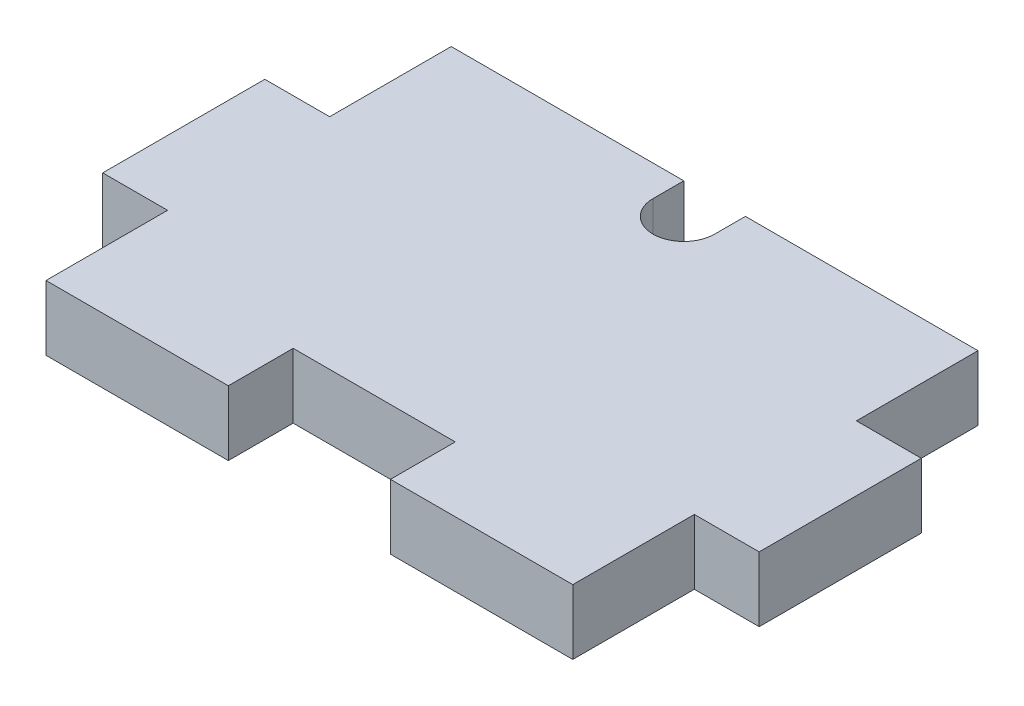
from build123d import *

# Parameters (mm, degrees)
SKETCH1_W           = 32.5
SKETCH1_H           = 25
BOSS_EXTRUDE1_DEPTH = 4
SKETCH2_R           = 1.9
SKETCH2_W           = 3.8
SKETCH2_H           = 1.9
CUT_EXTRUDE5_DEPTH  = 5
SKETCH3_W           = 4
SKETCH3_H           = 10
BOSS_EXTRUDE2_DEPTH = 4
SKETCH4_W           = 10
SKETCH4_H           = 4
CUT_EXTRUDE6_DEPTH  = 5


with BuildPart() as part:
    # Sketch1 → Boss-Extrude1 (new body)
    with BuildSketch(Plane(origin=(0, 0, 0), x_dir=(1, 0, 0), z_dir=(0, 1, 0))):
        with Locations((16.25, -12.5)):
            Rectangle(SKETCH1_W, SKETCH1_H)
    extrude(amount=BOSS_EXTRUDE1_DEPTH)

    # Sketch2 → Cut-Extrude5 (cut, through all)
    with BuildSketch(Plane(origin=(0, 4, 0), x_dir=(1, 0, 0), z_dir=(0, 1, 0))):
        with Locations((16.25, -1.9)):
            Circle(SKETCH2_R)
        with Locations((16.25, -0.95)):
            Rectangle(SKETCH2_W, SKETCH2_H)
    extrude(amount=-CUT_EXTRUDE5_DEPTH, mode=Mode.SUBTRACT)

    # Sketch3 → Boss-Extrude2 (add, through all)
    with BuildSketch(Plane(origin=(0, 4, 0), x_dir=(1, 0, 0), z_dir=(0, 1, 0))):
        with Locations((-2, -12.5)):
            Rectangle(SKETCH3_W, SKETCH3_H)
        with Locations((34.5, -12.5)):
            Rectangle(SKETCH3_W, SKETCH3_H)
    extrude(amount=-BOSS_EXTRUDE2_DEPTH)

    # Sketch4 → Cut-Extrude6 (cut, through all)
    with BuildSketch(Plane(origin=(0, 4, 0), x_dir=(1, 0, 0), z_dir=(0, 1, 0))):
        with Locations((16.25, -23)):
            Rectangle(SKETCH4_W, SKETCH4_H)
    extrude(amount=-CUT_EXTRUDE6_DEPTH, mode=Mode.SUBTRACT)


solid = part.part
